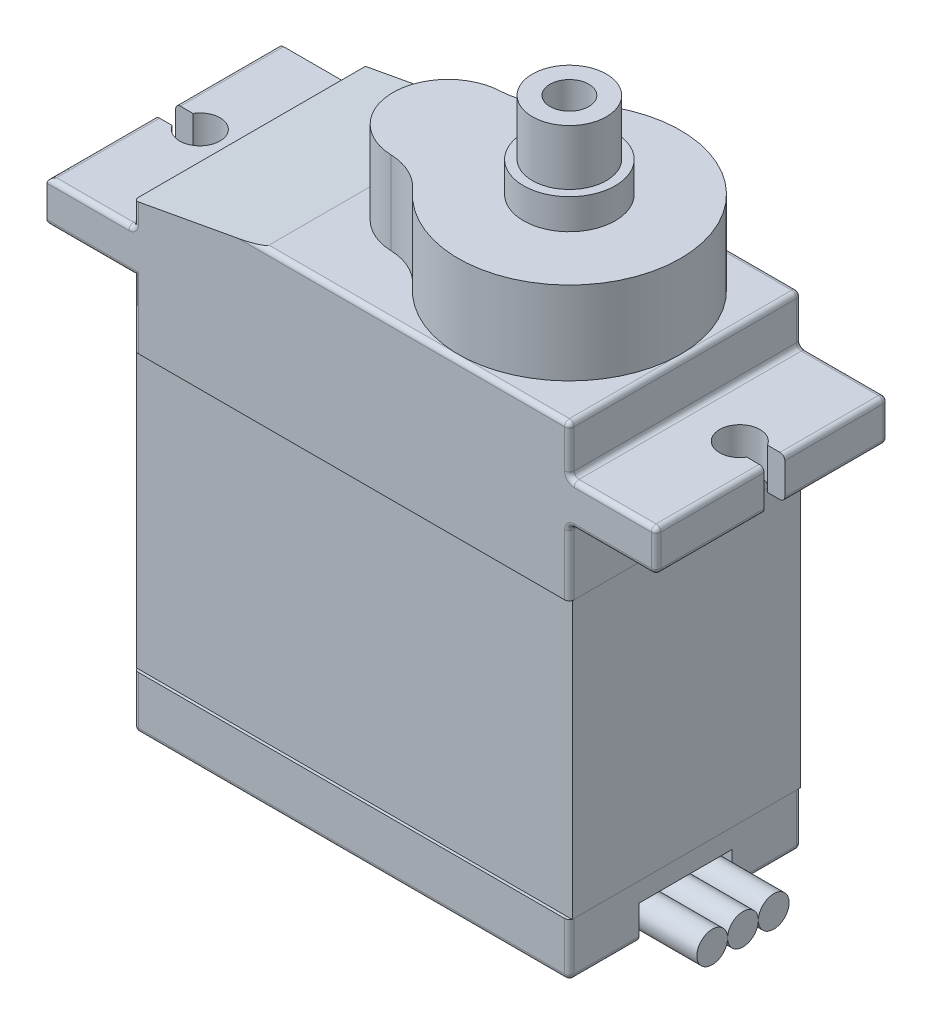
from build123d import *

# Parameters (mm, degrees)
CROQUIS1_W                   = 22.67
CROQUIS1_H                   = 12.06
SALIENTE_EXTRUIR1_DEPTH      = 25.15
CROQUIS2_W                   = 12.06
CROQUIS2_H                   = 2.13
SALIENTE_EXTRUIR2_DEPTH      = 4.51
CROQUIS5_W                   = 12.06
CROQUIS5_H                   = 2.13
SALIENTE_EXTRUIR3_DEPTH      = 4.51
REDONDEO1_R                  = 0.25
CORTAR_EXTRUIR12_DEPTH       = 4.51
SALIENTE_EXTRUIR4_DEPTH      = 4.32
CROQUIS9_R                   = 2.385
SALIENTE_EXTRUIR5_DEPTH      = 1.58
CROQUIS10_R                  = 2.385
SALIENTE_EXTRUIR6_DEPTH      = 2.88
CROQUIS11_R                  = 1.01
CORTAR_EXTRUIR13_DEPTH       = 3.88
CROQUIS12_R                  = 2.385
CROQUIS12_R_2                = 1.925
CORTAR_EXTRUIR14_DEPTH       = 2.88
CORTAR_EXTRUIR15_DEPTH       = 16.88
CROQUIS14_W                  = 22.17
CROQUIS14_H                  = 14.33
CORTAR_EXTRUIR16_DEPTH       = 16.88
CROQUIS16_W                  = 11.56
CROQUIS16_H                  = 14.354716837
CORTAR_EXTRUIR17_DEPTH       = 27.88
CROQUIS17_W                  = 22.67
CROQUIS17_H                  = 14.354716837
CORTAR_EXTRUIR18_DEPTH       = 27.88
CORTAR_EXTRUIR18_DEPTH_BACK  = 27.88
CROQUIS18_W                  = 22.67
CROQUIS18_H                  = 14.354716837
SALIENTE_EXTRUIR7_DEPTH      = 5.88
SALIENTE_EXTRUIR7_DEPTH_BACK = 6
CROQUIS19_W                  = 4.84
CROQUIS19_H                  = 1.754840309
CORTAR_EXTRUIR19_DEPTH       = 1.6
CROQUIS20_R                  = 0.8
SALIENTE_EXTRUIR8_DEPTH      = 4.6
SALIENTE_EXTRUIR8_2_DEPTH    = 4.6
SALIENTE_EXTRUIR8_3_DEPTH    = 4.6


with BuildPart() as part:
    # Croquis1 → Saliente-Extruir1 (new body)
    with BuildSketch(Plane(origin=(0, 0, 0), x_dir=(1, 0, 0), z_dir=(0, 1, 0))):
        Rectangle(CROQUIS1_W, CROQUIS1_H)
    extrude(amount=SALIENTE_EXTRUIR1_DEPTH)

    # Croquis2 → Saliente-Extruir2 (add)
    with BuildSketch(Plane(origin=(11.335, 0, 0), x_dir=(0, 0, -1), z_dir=(1, 0, 0))):
        with Locations((0, 21.595)):
            Rectangle(CROQUIS2_W, CROQUIS2_H)
    extrude(amount=SALIENTE_EXTRUIR2_DEPTH)

    # Croquis5 → Saliente-Extruir3 (add)
    with BuildSketch(Plane.ZY.offset(11.335)):
        with Locations((0, 21.595)):
            Rectangle(CROQUIS5_W, CROQUIS5_H)
    extrude(amount=SALIENTE_EXTRUIR3_DEPTH)

    # Redondeo1
    redondeo1_edges = [part.edges().sort_by_distance(p)[0] for p in [
        (-11.335, 23.905, 6.03),
        (11.335, 10.265, 6.03),
        (11.335, 23.905, 6.03),
        (11.335, 23.905, -6.03),
        (11.335, 10.265, -6.03),
        (11.335, 0, 0),
        (0, 0, -6.03),
        (0, 0, 6.03),
        (-11.335, 0, 0),
        (-11.335, 10.265, -6.03),
        (-11.335, 10.265, 6.03),
        (-13.59, 20.53, 6.03),
        (-13.59, 22.66, 6.03),
        (0, 25.15, -6.03),
        (0, 25.15, 6.03),
        (-11.335, 22.66, 0),
        (-11.335, 25.15, 0),
        (11.335, 25.15, 0),
        (13.59, 20.53, 6.03),
        (13.59, 22.66, 6.03),
        (13.59, 22.66, -6.03),
        (13.59, 20.53, -6.03),
        (11.335, 20.53, 0),
        (11.335, 22.66, 0),
        (15.845, 21.595, -6.03),
        (15.845, 21.595, 6.03),
        (15.845, 20.53, 0),
        (15.845, 22.66, 0),
        (-15.845, 20.53, 0),
        (-15.845, 22.66, 0),
    ]]
    fillet(redondeo1_edges, radius=REDONDEO1_R)

    # Croquis6 → Cortar-Extruir12 (cut)
    with BuildSketch(Plane(origin=(0, 22.66, 0), x_dir=(1, 0, 0), z_dir=(0, 1, 0))):
        with BuildLine():
            Line((-14.945499861, 0.665), (-15.845, 0.665))
            Line((-15.845, 0.665), (-15.845, -0.415))
            Line((-15.845, -0.415), (-14.945499861, -0.415))
            ThreePointArc((-14.945499861, -0.415), (-12.995, 0.125), (-14.945499861, 0.665))
        make_face()
        with BuildLine():
            Line((15.845, -0.415), (14.945499861, -0.415))
            ThreePointArc((14.945499861, -0.415), (12.995, 0.125), (14.945499861, 0.665))
            Line((14.945499861, 0.665), (15.845, 0.665))
            Line((15.845, 0.665), (15.845, -0.415))
        make_face()
    extrude(amount=-CORTAR_EXTRUIR12_DEPTH, mode=Mode.SUBTRACT)

    # Croquis13 → Cortar-Extruir15 (cut)
    with BuildSketch(Plane.XY.offset(6.03)):
        Polygon((-4.540532383, 25.15), (-11.335, 23.905), (-11.335, 25.15), align=None)
    extrude(amount=-CORTAR_EXTRUIR15_DEPTH, mode=Mode.SUBTRACT)

    # Croquis14 → Cortar-Extruir16 (cut)
    with BuildSketch(Plane.XY.offset(6.03)):
        with Locations((0, 9.935)):
            Rectangle(CROQUIS14_W, CROQUIS14_H)
    extrude(amount=-CORTAR_EXTRUIR16_DEPTH, mode=Mode.SUBTRACT)

    # Croquis16 → Cortar-Extruir17 (cut)
    with BuildSketch(Plane.ZY.offset(11.335)):
        with Locations((0, 9.932198727)):
            Rectangle(CROQUIS16_W, CROQUIS16_H)
    extrude(amount=-CORTAR_EXTRUIR17_DEPTH, mode=Mode.SUBTRACT)

    # Croquis17 → Cortar-Extruir18 (cut, two sides)
    with BuildSketch(Plane.XY) as cortar_extruir18_sk:
        with Locations((0, 9.932198727)):
            Rectangle(CROQUIS17_W, CROQUIS17_H)
    extrude(amount=CORTAR_EXTRUIR18_DEPTH, mode=Mode.SUBTRACT)
    extrude(cortar_extruir18_sk.sketch, amount=-CORTAR_EXTRUIR18_DEPTH_BACK, mode=Mode.SUBTRACT)

    # Croquis19 → Cortar-Extruir19 (cut)
    with BuildSketch(Plane(origin=(11.335, 0, 0), x_dir=(0, 0, -1), z_dir=(1, 0, 0))):
        with Locations((0, 0.877420155)):
            Rectangle(CROQUIS19_W, CROQUIS19_H)
    extrude(amount=-CORTAR_EXTRUIR19_DEPTH, mode=Mode.SUBTRACT)


with BuildPart() as body_2:
    # Croquis8 → Saliente-Extruir4 (new body)
    with BuildSketch(Plane(origin=(0, 25.15, 0), x_dir=(1, 0, 0), z_dir=(0, 1, 0))):
        with BuildLine():
            ThreePointArc((0.994686763, -3.850921942), (11.085, 0), (0.994686763, 3.850921942))
            ThreePointArc((0.994686763, 3.850921942), (0.038958362, 3.138827688), (-1.119352695, 2.85809561))
            ThreePointArc((-1.119352695, 2.85809561), (-3.875, 0), (-1.119352695, -2.85809561))
            ThreePointArc((-1.119352695, -2.85809561), (0.038958362, -3.138827688), (0.994686763, -3.850921942))
        make_face()
    extrude(amount=SALIENTE_EXTRUIR4_DEPTH)


with BuildPart() as body_3:
    # Croquis9 → Saliente-Extruir5 (new body)
    with BuildSketch(Plane(origin=(0, 29.47, 0), x_dir=(1, 0, 0), z_dir=(0, 1, 0))):
        with Locations((5.305, 0)):
            Circle(CROQUIS9_R)
    extrude(amount=SALIENTE_EXTRUIR5_DEPTH)


with BuildPart() as body_4:
    # Croquis10 → Saliente-Extruir6 (new body)
    with BuildSketch(Plane(origin=(0, 31.05, 0), x_dir=(1, 0, 0), z_dir=(0, 1, 0))):
        with Locations((5.305, 0)):
            Circle(CROQUIS10_R)
    extrude(amount=SALIENTE_EXTRUIR6_DEPTH)


with BuildPart() as cortar_extruir13_tool:
    # Croquis11 → Cortar-Extruir13 (new body)
    with BuildSketch(Plane(origin=(0, 33.93, 0), x_dir=(1, 0, 0), z_dir=(0, 1, 0))):
        with Locations((5.305, 0)):
            Circle(CROQUIS11_R)
    extrude(amount=-CORTAR_EXTRUIR13_DEPTH)


with BuildPart() as body_3_1:
    add(body_3.part)

    # Cortar-Extruir13: cut by cortar_extruir13_tool
    add(cortar_extruir13_tool.part, mode=Mode.SUBTRACT)


with BuildPart() as body_4_1:
    add(body_4.part)

    # Cortar-Extruir13: cut by cortar_extruir13_tool
    add(cortar_extruir13_tool.part, mode=Mode.SUBTRACT)

    # Croquis12 → Cortar-Extruir14 (cut)
    with BuildSketch(Plane(origin=(0, 33.93, 0), x_dir=(1, 0, 0), z_dir=(0, 1, 0))):
        with Locations((5.305, 0)):
            Circle(CROQUIS12_R)
        with Locations((5.305, 0)):
            Circle(CROQUIS12_R_2, mode=Mode.SUBTRACT)
    extrude(amount=-CORTAR_EXTRUIR14_DEPTH, mode=Mode.SUBTRACT)


with BuildPart() as body_5:
    # Croquis18 → Saliente-Extruir7 (new body, two sides)
    with BuildSketch(Plane.XY) as saliente_extruir7_sk:
        with Locations((0, 9.932198727)):
            Rectangle(CROQUIS18_W, CROQUIS18_H)
    extrude(amount=SALIENTE_EXTRUIR7_DEPTH)
    extrude(saliente_extruir7_sk.sketch, amount=-SALIENTE_EXTRUIR7_DEPTH_BACK)


with BuildPart() as body_6:
    # Croquis20 → Saliente-Extruir8 (new body)
    with BuildSketch(Plane(origin=(9.735, 0, 0), x_dir=(0, 0, -1), z_dir=(1, 0, 0))):
        with Locations((-1.6, 0.877420155)):
            Circle(CROQUIS20_R)
    extrude(amount=SALIENTE_EXTRUIR8_DEPTH)


with BuildPart() as body_7:
    # Croquis20 → Saliente-Extruir8 2 (new body)
    with BuildSketch(Plane(origin=(9.735, 0, 0), x_dir=(0, 0, -1), z_dir=(1, 0, 0))):
        with Locations((0, 0.877420155)):
            Circle(CROQUIS20_R)
    extrude(amount=SALIENTE_EXTRUIR8_2_DEPTH)


with BuildPart() as body_8:
    # Croquis20 → Saliente-Extruir8 3 (new body)
    with BuildSketch(Plane(origin=(9.735, 0, 0), x_dir=(0, 0, -1), z_dir=(1, 0, 0))):
        with Locations((1.6, 0.877420155)):
            Circle(CROQUIS20_R)
    extrude(amount=SALIENTE_EXTRUIR8_3_DEPTH)


solid = Compound([part.part, body_2.part, body_3_1.part, body_4_1.part, body_5.part, body_6.part, body_7.part, body_8.part])
